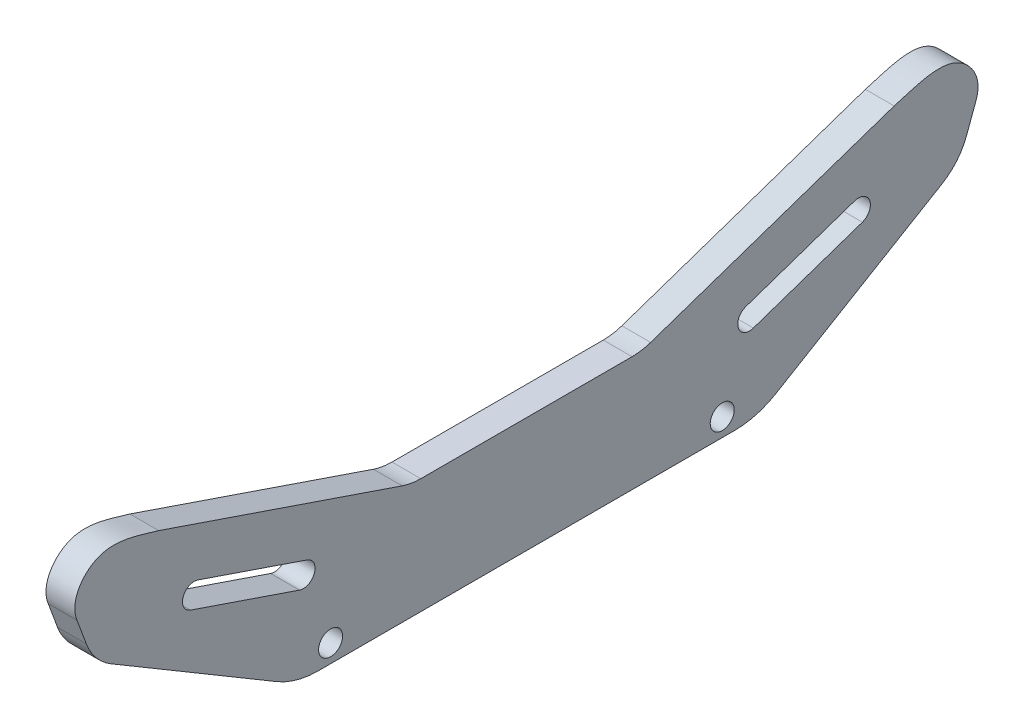
from build123d import *

# Parameters (mm, degrees)
BOSS_EXTRUDE1_DEPTH = 6.35
SLOTS_DEPTH         = 7.3500001
SKETCH3_R           = 2.65
HOLES_DEPTH         = 7.3500001
FILLET1_R           = 12.7
FILLET2_R           = 17.78


with BuildPart() as part:
    # Sketch1 → Boss-Extrude1 (new body)
    with BuildSketch(Plane(origin=(0, 0, 0), x_dir=(0, 0, -1), z_dir=(1, 0, 0))):
        with BuildLine():
            Line((50.8, 0), (-50.8, 0))
            Line((-50.8, 0), (-95.491911785, 26.510580519))
            Line((-95.491911785, 26.510580519), (-99.095159206, 36.267222623))
            add(Edge.make_bspline(
                [(-81.095679658, 44.383857392), (-84.793404741, 45.36773864), (-94.554651266, 49.479684382), (-100.787803101, 40.484157915), (-99.095159206, 36.267222623)],
                knots=[0, 0, 0, 0, 0.528781937, 1, 1, 1, 1], degree=3))
            Line((-81.095679658, 44.383857392), (-25.4, 25.4))
            Line((-25.4, 25.4), (25.4, 25.4))
            Line((25.4, 25.4), (81.095679658, 44.383857392))
            add(Edge.make_bspline(
                [(81.095679658, 44.383857392), (84.793404741, 45.36773864), (94.554651266, 49.479684382), (100.787803101, 40.484157915), (99.095159206, 36.267222623)],
                knots=[0, 0, 0, 0, 0.528781937, 1, 1, 1, 1], degree=3))
            Line((99.095159206, 36.267222623), (95.491911785, 26.510580519))
            Line((95.491911785, 26.510580519), (50.8, 0))
        make_face()
    extrude(amount=BOSS_EXTRUDE1_DEPTH)

    # Sketch2 → slots (cut, through all)
    with BuildSketch(Plane.ZY):
        with BuildLine():
            Line((-72.404954671, 30.615105796), (-48.363160058, 22.420466586))
            ThreePointArc((-48.363160058, 22.420466586), (-46.741010292, 19.120674147), (-50.040802731, 17.498524382))
            Line((-50.040802731, 17.498524382), (-74.082597344, 25.693163592))
            ThreePointArc((-74.082597344, 25.693163592), (-75.70474711, 28.992956031), (-72.404954671, 30.615105796))
        make_face()
        with BuildLine():
            Line((72.404954671, 30.615105796), (48.363160058, 22.420466586))
            ThreePointArc((48.363160058, 22.420466586), (46.741010292, 19.120674147), (50.040802731, 17.498524382))
            Line((50.040802731, 17.498524382), (74.082597344, 25.693163592))
            ThreePointArc((74.082597344, 25.693163592), (75.70474711, 28.992956031), (72.404954671, 30.615105796))
        make_face()
    extrude(amount=-SLOTS_DEPTH, mode=Mode.SUBTRACT)

    # Sketch3 → holes (cut, through all)
    with BuildSketch(Plane.ZY):
        with Locations((-43.18, 4)):
            Circle(SKETCH3_R)
        with Locations((43.18, 4)):
            Circle(SKETCH3_R)
    extrude(amount=-HOLES_DEPTH, mode=Mode.SUBTRACT)

    # Fillet1
    fillet1_edges = [part.edges().sort_by_distance(p)[0] for p in [
        (3.175, 26.510580519, 95.491911785),
        (3.175, 25.4, 25.4),
        (3.175, 25.4, -25.4),
        (3.175, 26.510580519, -95.491911785),
    ]]
    fillet(fillet1_edges, radius=FILLET1_R)

    # Fillet2
    fillet2_edges = [part.edges().sort_by_distance(p)[0] for p in [
        (3.175, 0, -50.8),
        (3.175, 0, 50.8),
    ]]
    fillet(fillet2_edges, radius=FILLET2_R)


solid = part.part
